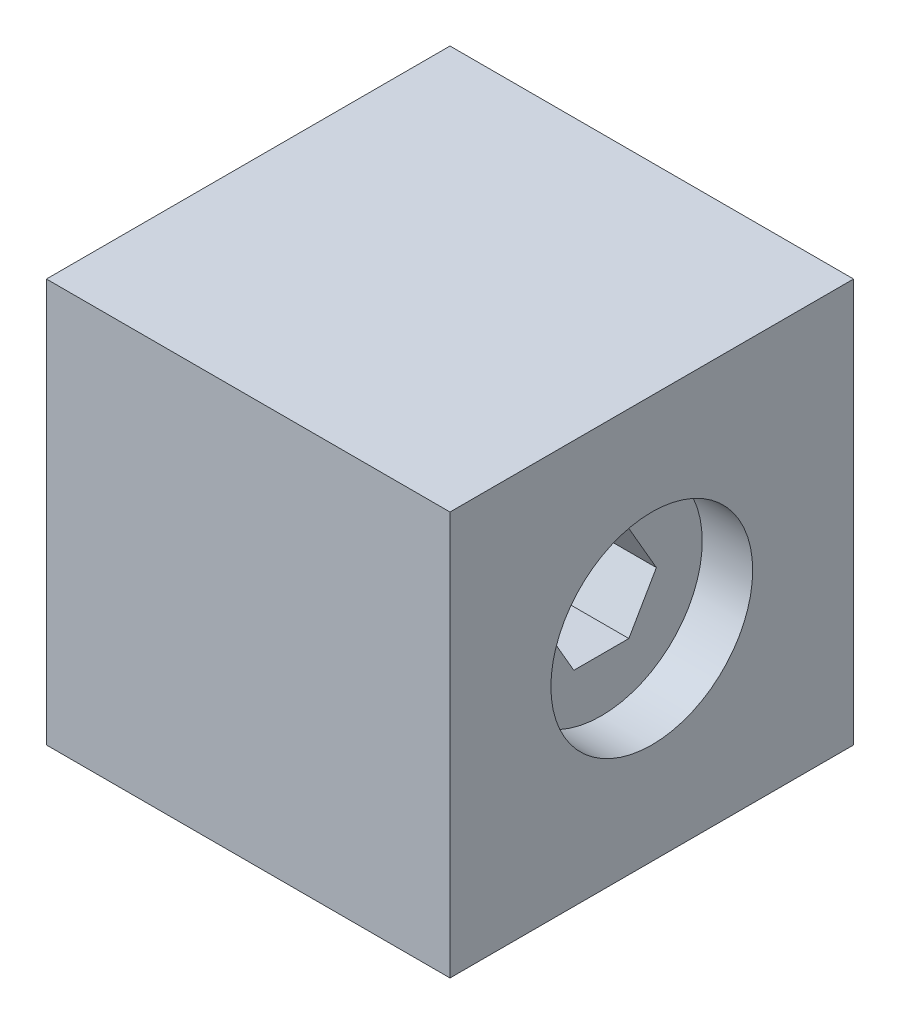
from build123d import *

# Parameters (mm, degrees)
SKETCH2_W           = 50.8
SKETCH2_H           = 50.8
BOSS_EXTRUDE1_DEPTH = 50.8
SKETCH3_W           = 25.4
SKETCH3_H           = 25.4
SKETCH3_W_2         = 22.352
SKETCH3_H_2         = 22.352
CUT_EXTRUDE1_DEPTH  = 15.24
CUT_EXTRUDE2_DEPTH  = 51.8
SKETCH5_R           = 12.7
CUT_EXTRUDE3_DEPTH  = 6.35


with BuildPart() as part:
    # Sketch2 → Boss-Extrude1 (new body)
    with BuildSketch(Plane(origin=(0, 0, 0), x_dir=(1, 0, 0), z_dir=(0, 1, 0))):
        Rectangle(SKETCH2_W, SKETCH2_H)
    extrude(amount=BOSS_EXTRUDE1_DEPTH)

    # Sketch3 → Cut-Extrude1 (cut)
    with BuildSketch(Plane.XZ):
        Rectangle(SKETCH3_W, SKETCH3_H)
        Rectangle(SKETCH3_W_2, SKETCH3_H_2, mode=Mode.SUBTRACT)
    extrude(amount=-CUT_EXTRUDE1_DEPTH, mode=Mode.SUBTRACT)

    # Sketch4 → Cut-Extrude2 (cut, through all)
    with BuildSketch(Plane(origin=(25.4, 0, 0), x_dir=(0, 0, -1), z_dir=(1, 0, 0))):
        Polygon((6.92820323, 25.4), (3.464101615, 31.4), (-3.464101615, 31.4), (-6.92820323, 25.4), (-3.464101615, 19.4), (3.464101615, 19.4), align=None)
    extrude(amount=-CUT_EXTRUDE2_DEPTH, mode=Mode.SUBTRACT)

    # Sketch5 → Cut-Extrude3 (cut)
    with BuildSketch(Plane(origin=(25.4, 0, 0), x_dir=(0, 0, -1), z_dir=(1, 0, 0))):
        with Locations((0, 25.4)):
            Circle(SKETCH5_R)
    extrude(amount=-CUT_EXTRUDE3_DEPTH, mode=Mode.SUBTRACT)


solid = part.part
